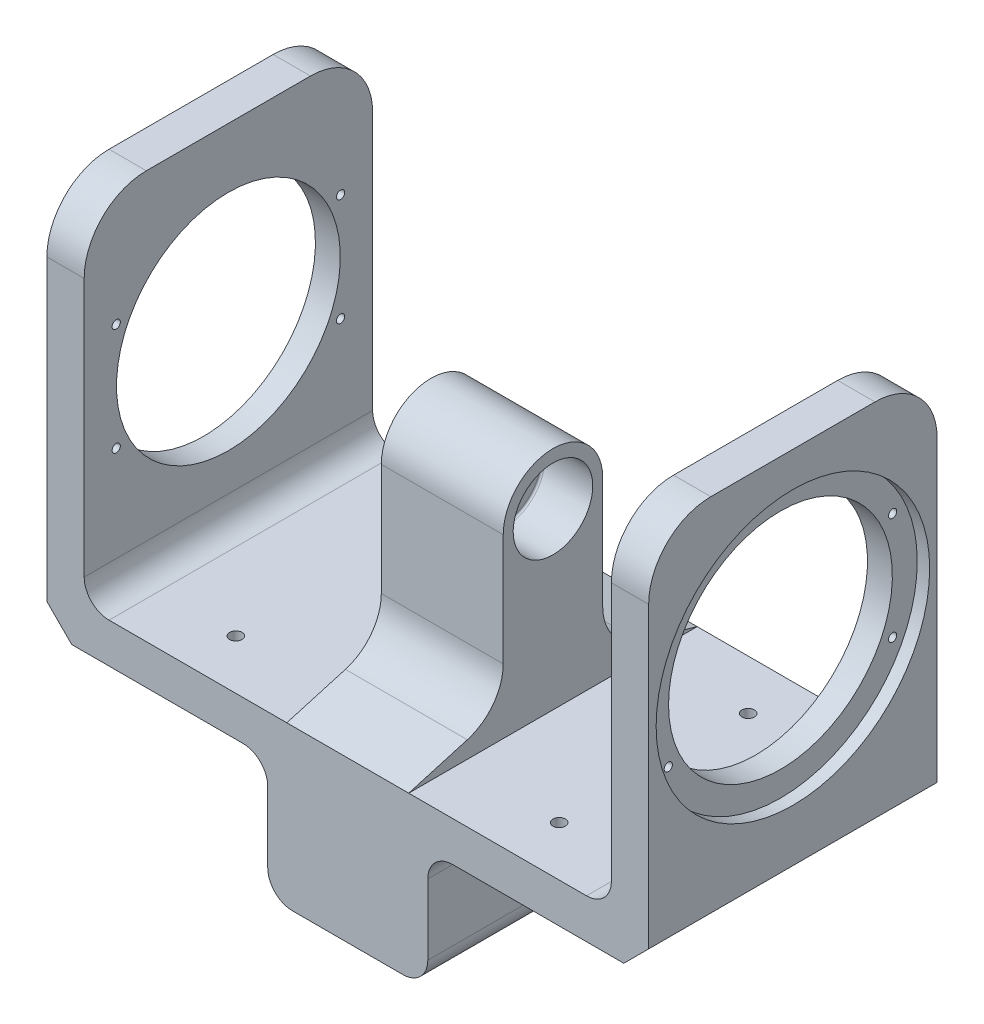
from build123d import *

# Parameters (mm, degrees)
BOSS_EXTRUDE1_DEPTH       = 116
SKETCH5_R                 = 16
CUT_EXTRUDE1_DEPTH        = 20
CUT_EXTRUDE2_REACH        = 6.51
SKETCH6_R                 = 10
CUT_EXTRUDE4_REACH        = 17
SKETCH8_R                 = 45
CUT_EXTRUDE5_DEPTH        = 106
FILLET3_R                 = 25
M6X1_0_TAPPED_HOLE1_D     = 5
M6X1_0_TAPPED_HOLE1_DEPTH = 16
SKETCH21_R                = 55
CUT_EXTRUDE7_DEPTH        = 5
M4X0_7_TAPPED_HOLE1_D     = 3.3
FILLET4_R                 = 0.8
CHAMFER1_SIZE             = 10
SKETCH25_W                = 64.356
SKETCH25_H                = 48.356
BOSS_EXTRUDE2_DEPTH       = 116
CUT_EXTRUDE8_DEPTH        = 106
FILLET6_R                 = 10
FILLET7_R                 = 10
FILLET8_R                 = 10


with BuildPart() as part:
    # Sketch1 → Boss-Extrude1 (new body)
    with BuildSketch(Plane.XY):
        Polygon((0, 0), (-106, 0), (-121, 0), (-121, 155), (-106, 155), (-106, 16), (-24.51, 16), (-24.51, 107), (0, 107), align=None)
    extrude(amount=-BOSS_EXTRUDE1_DEPTH)

    # Sketch5 → Cut-Extrude1 (cut)
    with BuildSketch(Plane.ZY.offset(24.51)):
        with Locations((-58, 86)):
            Circle(SKETCH5_R)
    extrude(amount=-CUT_EXTRUDE1_DEPTH, mode=Mode.SUBTRACT)

    # Sketch6 → Cut-Extrude2 (cut, up to next)
    with BuildSketch(Plane.ZY.offset(4.51), mode=Mode.PRIVATE) as cut_extrude2_sk1:
        with Locations((-58, 86)):
            Circle(SKETCH6_R)
    cut_extrude2_tool1 = extrude(cut_extrude2_sk1.sketch, amount=-CUT_EXTRUDE2_REACH, mode=Mode.PRIVATE) & part.part
    add(cut_extrude2_tool1.solids().sort_by_distance((-4.51, 86, -58))[0], mode=Mode.SUBTRACT)

    # Sketch8 → Cut-Extrude4 (cut, up to next)
    with BuildSketch(Plane(origin=(-106, 0, 0), x_dir=(0, 0, -1), z_dir=(1, 0, 0)), mode=Mode.PRIVATE) as cut_extrude4_sk1:
        with Locations((58, 86)):
            Circle(SKETCH8_R)
    cut_extrude4_tool1 = extrude(cut_extrude4_sk1.sketch, amount=-CUT_EXTRUDE4_REACH, mode=Mode.PRIVATE) & part.part
    add(cut_extrude4_tool1.solids().sort_by_distance((-106, 86, -58))[0], mode=Mode.SUBTRACT)

    # Sketch10 → Cut-Extrude5 (cut)
    with BuildSketch(Plane(origin=(0, 0, 0), x_dir=(0, 0, -1), z_dir=(1, 0, 0))):
        with BuildLine():
            Line((0, 107), (0, 16))
            Line((0, 16), (23.561161531, 22.820336233))
            ThreePointArc((23.561161531, 22.820336233), (33.987858372, 30.015449722), (38, 42.031621521))
            Line((38, 42.031621521), (38, 87))
            ThreePointArc((38, 87), (43.857864376, 101.142135624), (58, 107))
            Line((58, 107), (0, 107))
        make_face()
        with BuildLine():
            Line((116, 107), (58, 107))
            ThreePointArc((58, 107), (72.142135624, 101.142135624), (78, 87))
            Line((78, 87), (78, 42.031621521))
            ThreePointArc((78, 42.031621521), (82.012141628, 30.015449722), (92.438838469, 22.820336233))
            Line((92.438838469, 22.820336233), (116, 16))
            Line((116, 16), (116, 107))
        make_face()
    extrude(amount=-CUT_EXTRUDE5_DEPTH, mode=Mode.SUBTRACT)

    # Fillet3
    fillet3_edges = [part.edges().sort_by_distance(p)[0] for p in [
        (-113.5, 155, 0),
        (-113.5, 155, -116),
    ]]
    fillet(fillet3_edges, radius=FILLET3_R)

    # M6x1.0 Tapped Hole1
    with Locations(Plane(origin=(0, 0, 0), x_dir=(-1, 0, 0), z_dir=(0, -1, 0))):
        with Locations((65, 20), (65, 96)):
            Hole(M6X1_0_TAPPED_HOLE1_D / 2, depth=M6X1_0_TAPPED_HOLE1_DEPTH)

    # Sketch21 → Cut-Extrude7 (cut)
    with BuildSketch(Plane.ZY.offset(121)):
        with Locations((-58, 86)):
            Circle(SKETCH21_R)
    extrude(amount=-CUT_EXTRUDE7_DEPTH, mode=Mode.SUBTRACT)

    # M4x0.7 Tapped Hole1 (through all)
    with Locations(Plane.ZY.offset(116)):
        with Locations((-103.10855484, 107.568919311), (-12.89144516, 107.568919311), (-12.89144516, 64.431080689), (-103.10855484, 64.431080689)):
            Hole(M4X0_7_TAPPED_HOLE1_D / 2)

    # Mirror1: part across plane


with BuildPart() as part_1:
    add(part.part)
    add(part.part.mirror(Plane(origin=(0, 107, -116), x_dir=(0, 0, 1), z_dir=(1, 0, 0))))

    # Fillet4
    fillet4_edges = [part_1.edges().sort_by_distance(p)[0] for p in [
        (4.51, 86, -74),
        (-4.51, 86, -74),
    ]]
    fillet(fillet4_edges, radius=FILLET4_R)

    # Chamfer1
    chamfer1_edges = [part_1.edges().sort_by_distance(p)[0] for p in [
        (-121, 0, -58),
        (121, 0, -58),
    ]]
    chamfer(chamfer1_edges, length=CHAMFER1_SIZE)

    # Sketch25 → Boss-Extrude2 (add)
    with BuildSketch(Plane.XY):
        with Locations((0, -24.178)):
            Rectangle(SKETCH25_W, SKETCH25_H)
    extrude(amount=-BOSS_EXTRUDE2_DEPTH)

    # Sketch27 → Cut-Extrude8 (cut)
    with BuildSketch(Plane(origin=(0, 0, -116), x_dir=(-1, 0, 0), z_dir=(0, 0, -1))):
        with BuildLine():
            Line((-21.05025, -43.356), (21.05025, -43.356))
            ThreePointArc((21.05025, -43.356), (25.383223578, -41.561223578), (27.178, -37.22825))
            Line((27.178, -37.22825), (27.178, 4.87225))
            ThreePointArc((27.178, 4.87225), (25.383223578, 9.205223578), (21.05025, 11))
            Line((21.05025, 11), (-21.05025, 11))
            ThreePointArc((-21.05025, 11), (-25.383223578, 9.205223578), (-27.178, 4.87225))
            Line((-27.178, 4.87225), (-27.178, -37.22825))
            ThreePointArc((-27.178, -37.22825), (-25.383223578, -41.561223578), (-21.05025, -43.356))
        make_face()
    extrude(amount=-CUT_EXTRUDE8_DEPTH, mode=Mode.SUBTRACT)

    # Fillet6
    fillet6_edges = [part_1.edges().sort_by_distance(p)[0] for p in [
        (-32.178, 0, -58),
        (32.178, 0, -58),
    ]]
    fillet(fillet6_edges, radius=FILLET6_R)

    # Fillet7
    fillet7_edges = [part_1.edges().sort_by_distance(p)[0] for p in [
        (-32.178, -48.356, -58),
        (32.178, -48.356, -58),
    ]]
    fillet(fillet7_edges, radius=FILLET7_R)

    # Fillet8
    fillet8_edges = [part_1.edges().sort_by_distance(p)[0] for p in [
        (-106, 16, -58),
        (106, 16, -58),
    ]]
    fillet(fillet8_edges, radius=FILLET8_R)


solid = part_1.part
